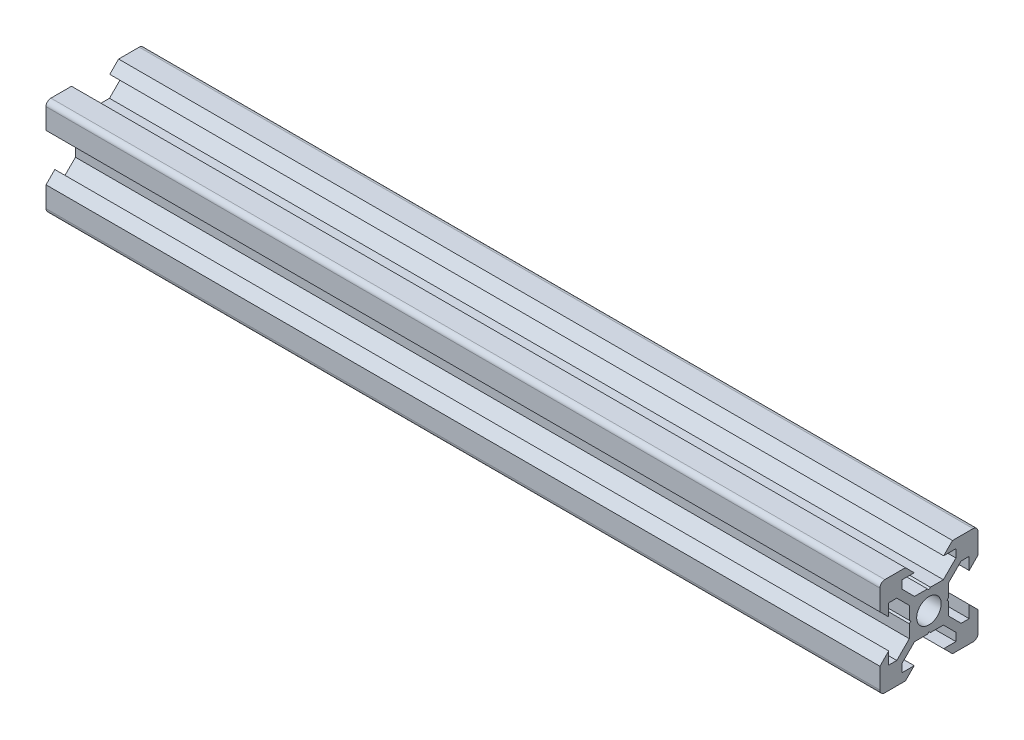
from build123d import *

# Parameters (mm, degrees)
SKETCH11_R                                  = 2.5
QUADRADO_PF20_11_PERFIL_2020_V_SLOT_1_DEPTH = 170


with BuildPart() as part:
    # Sketch11 → Quadrado PF20-11 - PERFIL 2020 V-SLOT(1) (new body)
    with BuildSketch(Plane.YZ):
        with BuildLine():
            Line((-4.8, 10), (-3, 8.2))
            Line((-3, 8.2), (-5.5, 8.2))
            Line((-5.5, 8.2), (-5.5, 6.560660172))
            Line((-5.5, 6.560660172), (-2.939339828, 4))
            Line((-2.939339828, 4), (-0.3, 4))
            Line((-0.3, 4), (0, 3.7))
            Line((0, 3.7), (0.3, 4))
            Line((0.3, 4), (2.939339828, 4))
            Line((2.939339828, 4), (5.5, 6.560660172))
            Line((5.5, 6.560660172), (5.5, 8.2))
            Line((5.5, 8.2), (3, 8.2))
            Line((3, 8.2), (4.8, 10))
            Line((4.8, 10), (9, 10))
            ThreePointArc((9, 10), (9.707106781, 9.707106781), (10, 9))
            Line((10, 9), (10, 4.8))
            Line((10, 4.8), (8.2, 3))
            Line((8.2, 3), (8.2, 5.5))
            Line((8.2, 5.5), (6.560660172, 5.5))
            Line((6.560660172, 5.5), (4, 2.939339828))
            Line((4, 2.939339828), (4, 0.3))
            Line((4, 0.3), (3.7, 0))
            Line((3.7, 0), (4, -0.3))
            Line((4, -0.3), (4, -2.939339828))
            Line((4, -2.939339828), (6.560660172, -5.5))
            Line((6.560660172, -5.5), (8.2, -5.5))
            Line((8.2, -5.5), (8.2, -3))
            Line((8.2, -3), (10, -4.8))
            Line((10, -4.8), (10, -9))
            ThreePointArc((10, -9), (9.707106781, -9.707106781), (9, -10))
            Line((9, -10), (4.8, -10))
            Line((4.8, -10), (3, -8.2))
            Line((3, -8.2), (5.5, -8.2))
            Line((5.5, -8.2), (5.5, -6.560660172))
            Line((5.5, -6.560660172), (2.939339828, -4))
            Line((2.939339828, -4), (0.3, -4))
            Line((0.3, -4), (0, -3.7))
            Line((0, -3.7), (-0.3, -4))
            Line((-0.3, -4), (-2.939339828, -4))
            Line((-2.939339828, -4), (-5.5, -6.560660172))
            Line((-5.5, -6.560660172), (-5.5, -8.2))
            Line((-5.5, -8.2), (-3, -8.2))
            Line((-3, -8.2), (-4.8, -10))
            Line((-4.8, -10), (-9, -10))
            ThreePointArc((-9, -10), (-9.707106781, -9.707106781), (-10, -9))
            Line((-10, -9), (-10, -4.8))
            Line((-10, -4.8), (-8.2, -3))
            Line((-8.2, -3), (-8.2, -5.5))
            Line((-8.2, -5.5), (-6.560660172, -5.5))
            Line((-6.560660172, -5.5), (-4, -2.939339828))
            Line((-4, -2.939339828), (-4, -0.3))
            Line((-4, -0.3), (-3.7, 0))
            Line((-3.7, 0), (-4, 0.3))
            Line((-4, 0.3), (-4, 2.939339828))
            Line((-4, 2.939339828), (-6.560660172, 5.5))
            Line((-6.560660172, 5.5), (-8.2, 5.5))
            Line((-8.2, 5.5), (-8.2, 3))
            Line((-8.2, 3), (-10, 4.8))
            Line((-10, 4.8), (-10, 9))
            ThreePointArc((-10, 9), (-9.707106781, 9.707106781), (-9, 10))
            Line((-9, 10), (-4.8, 10))
        make_face()
        Circle(SKETCH11_R, mode=Mode.SUBTRACT)
    extrude(amount=QUADRADO_PF20_11_PERFIL_2020_V_SLOT_1_DEPTH)


solid = part.part
